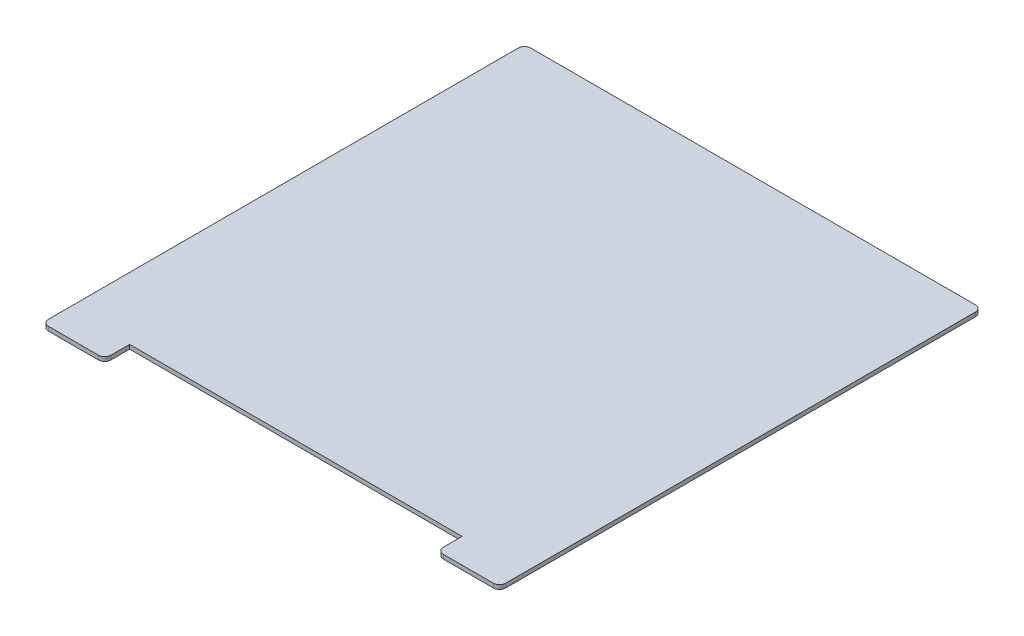
from build123d import *

# Parameters (mm, degrees)
BOSS_EXTRUDE1_DEPTH = 2
FILLET1_R           = 3


with BuildPart() as part:
    # Sketch1 → Boss-Extrude1 (new body)
    with BuildSketch(Plane(origin=(0, 0, 0), x_dir=(1, 0, 0), z_dir=(0, 1, 0))):
        Polygon((-160, -197.649746193), (-160, -185.649746193), (0, -185.649746193), (0, -197.649746193), (30, -197.649746193), (30, 34.350253807), (-190, 34.350253807), (-190, -197.649746193), align=None)
    extrude(amount=BOSS_EXTRUDE1_DEPTH)

    # Fillet1
    fillet1_edges = [part.edges().sort_by_distance(p)[0] for p in [
        (-190, 1, -34.350253807),
        (30, 1, -34.350253807),
        (30, 1, 197.649746193),
        (0, 1, 197.649746193),
        (-160, 1, 197.649746193),
        (-190, 1, 197.649746193),
    ]]
    fillet(fillet1_edges, radius=FILLET1_R)


solid = part.part
